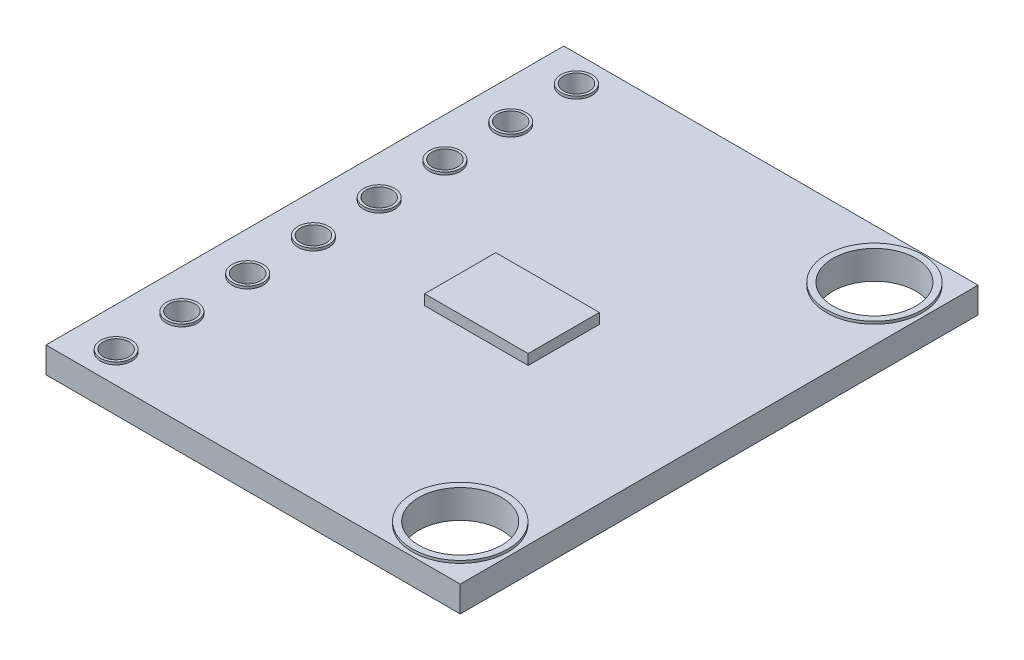
from build123d import *

# Parameters (mm, degrees)
SKETCH1_W                   = 16
SKETCH1_H                   = 20
BOSS_EXTRUDE1_DEPTH         = 1
SKETCH4_W                   = 4
SKETCH4_H                   = 2.75
BOSS_EXTRUDE3_DEPTH         = 0.4
IZIM1_R                     = 0.6
IZIM1_R_2                   = 0.5
Y_KSEKLIK_EKSTR_ZYON1_DEPTH = 0.1
IZIM3_R                     = 0.5
KES_EKSTR_ZYON2_DEPTH       = 20.1
IZIM4_R                     = 1.85
IZIM4_R_2                   = 1.6
Y_KSEKLIK_EKSTR_ZYON2_DEPTH = 0.1
IZIM5_R                     = 1.6
KES_EKSTR_ZYON3_DEPTH       = 10.1


with BuildPart() as part:
    # Sketch1 → Boss-Extrude1 (new body)
    with BuildSketch(Plane(origin=(0, 0, 0), x_dir=(1, 0, 0), z_dir=(0, 1, 0))):
        Rectangle(SKETCH1_W, SKETCH1_H)
    extrude(amount=BOSS_EXTRUDE1_DEPTH)

    # Çizim1 → Yükseklik-Ekstrüzyon1 (add)
    with BuildSketch(Plane(origin=(0, 1, 0), x_dir=(1, 0, 0), z_dir=(0, 1, 0))):
        with Locations((-6.400785843, -8.89)):
            Circle(IZIM1_R)
        with Locations((-6.400785843, -8.89)):
            Circle(IZIM1_R_2, mode=Mode.SUBTRACT)
        with Locations((-6.400785843, -6.35)):
            Circle(IZIM1_R)
        with Locations((-6.400785843, -6.35)):
            Circle(IZIM1_R_2, mode=Mode.SUBTRACT)
        with Locations((-6.400785843, -3.81)):
            Circle(IZIM1_R)
        with Locations((-6.400785843, -3.81)):
            Circle(IZIM1_R_2, mode=Mode.SUBTRACT)
        with Locations((-6.400785843, -1.27)):
            Circle(IZIM1_R)
        with Locations((-6.400785843, -1.27)):
            Circle(IZIM1_R_2, mode=Mode.SUBTRACT)
        with Locations((-6.400785843, 1.27)):
            Circle(IZIM1_R)
        with Locations((-6.400785843, 1.27)):
            Circle(IZIM1_R_2, mode=Mode.SUBTRACT)
        with Locations((-6.400785843, 3.81)):
            Circle(IZIM1_R)
        with Locations((-6.400785843, 3.81)):
            Circle(IZIM1_R_2, mode=Mode.SUBTRACT)
        with Locations((-6.400785843, 6.35)):
            Circle(IZIM1_R)
        with Locations((-6.400785843, 6.35)):
            Circle(IZIM1_R_2, mode=Mode.SUBTRACT)
        with Locations((-6.400785843, 8.89)):
            Circle(IZIM1_R)
        with Locations((-6.400785843, 8.89)):
            Circle(IZIM1_R_2, mode=Mode.SUBTRACT)
    extrude(amount=Y_KSEKLIK_EKSTR_ZYON1_DEPTH)

    # Çizim3 → Kes-Ekstrüzyon2 (cut)
    with BuildSketch(Plane(origin=(0, 1, 0), x_dir=(1, 0, 0), z_dir=(0, 1, 0))):
        with Locations((-6.400785843, -8.89)):
            Circle(IZIM3_R)
        with Locations((-6.400785843, -6.35)):
            Circle(IZIM3_R)
        with Locations((-6.400785843, -3.81)):
            Circle(IZIM3_R)
        with Locations((-6.400785843, -1.27)):
            Circle(IZIM3_R)
        with Locations((-6.400785843, 1.27)):
            Circle(IZIM3_R)
        with Locations((-6.400785843, 3.81)):
            Circle(IZIM3_R)
        with Locations((-6.400785843, 6.35)):
            Circle(IZIM3_R)
        with Locations((-6.400785843, 8.89)):
            Circle(IZIM3_R)
    extrude(amount=-KES_EKSTR_ZYON2_DEPTH, mode=Mode.SUBTRACT)

    # Çizim4 → Yükseklik-Ekstrüzyon2 (add)
    with BuildSketch(Plane(origin=(0, 1, 0), x_dir=(1, 0, 0), z_dir=(0, 1, 0))):
        with Locations((6, -8)):
            Circle(IZIM4_R)
        with Locations((6, -8)):
            Circle(IZIM4_R_2, mode=Mode.SUBTRACT)
        with Locations((6, 8)):
            Circle(IZIM4_R)
        with Locations((6, 8)):
            Circle(IZIM4_R_2, mode=Mode.SUBTRACT)
    extrude(amount=Y_KSEKLIK_EKSTR_ZYON2_DEPTH)

    # Çizim5 → Kes-Ekstrüzyon3 (cut)
    with BuildSketch(Plane(origin=(0, 1, 0), x_dir=(1, 0, 0), z_dir=(0, 1, 0))):
        with Locations((6, 8)):
            Circle(IZIM5_R)
        with Locations((6, -8)):
            Circle(IZIM5_R)
    extrude(amount=-KES_EKSTR_ZYON3_DEPTH, mode=Mode.SUBTRACT)


with BuildPart() as body_2:
    # Sketch4 → Boss-Extrude3 (new body)
    with BuildSketch(Plane(origin=(0, 1, 0), x_dir=(1, 0, 0), z_dir=(0, 1, 0))):
        Rectangle(SKETCH4_W, SKETCH4_H)
    extrude(amount=BOSS_EXTRUDE3_DEPTH)


solid = Compound([part.part, body_2.part])
